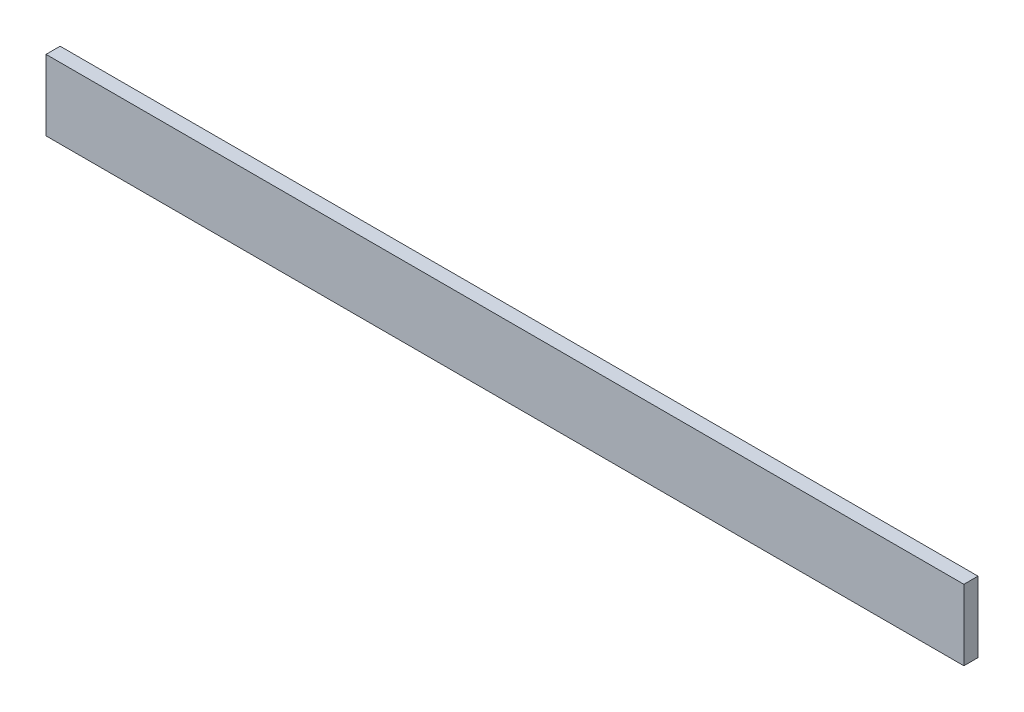
from build123d import *

# Parameters (mm, degrees)
SKETCH_1_W      = 10
SKETCH_1_H      = 50
EXTRUDE_1_DEPTH = 650


with BuildPart() as part:
    # Эскиз1 → Бобышка-Вытянуть1 (new body)
    with BuildSketch(Plane(origin=(0, 0, 0), x_dir=(0, 0, -1), z_dir=(1, 0, 0))):
        with Locations((5, 25)):
            Rectangle(SKETCH_1_W, SKETCH_1_H)
    extrude(amount=EXTRUDE_1_DEPTH)


solid = part.part
